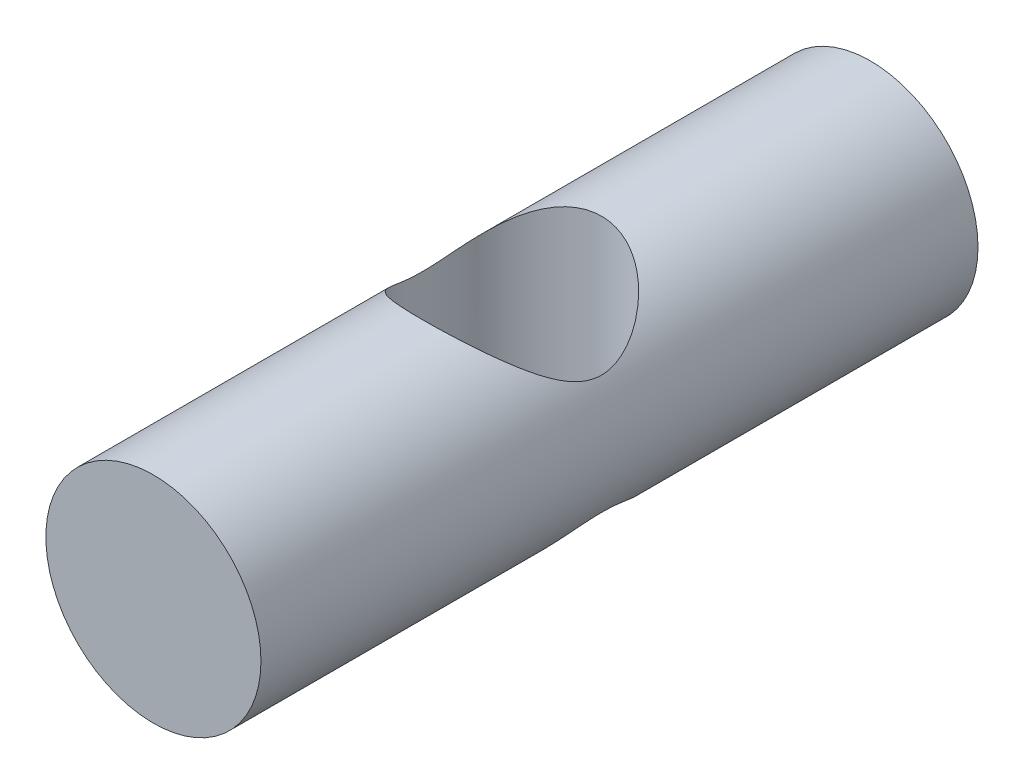
from build123d import *

# Parameters (mm, degrees)
SKETCH_1_R          = 6
EXTRUDE_1_DEPTH     = 20
SKETCH_3_R          = 5
CUT_EXTRUDE_1_DEPTH = 13


with BuildPart() as part:
    # 草图1 → 凸台-拉伸1 (new body, symmetric)
    with BuildSketch(Plane.XY):
        Circle(SKETCH_1_R)
    extrude(amount=EXTRUDE_1_DEPTH, both=True)

    # 草图3 → 切除-拉伸1 (cut, through all)
    with BuildSketch(Plane(origin=(0, 6, 0), x_dir=(1, 0, 0), z_dir=(0, 1, 0))):
        Circle(SKETCH_3_R)
    extrude(amount=-CUT_EXTRUDE_1_DEPTH, mode=Mode.SUBTRACT)


solid = part.part
